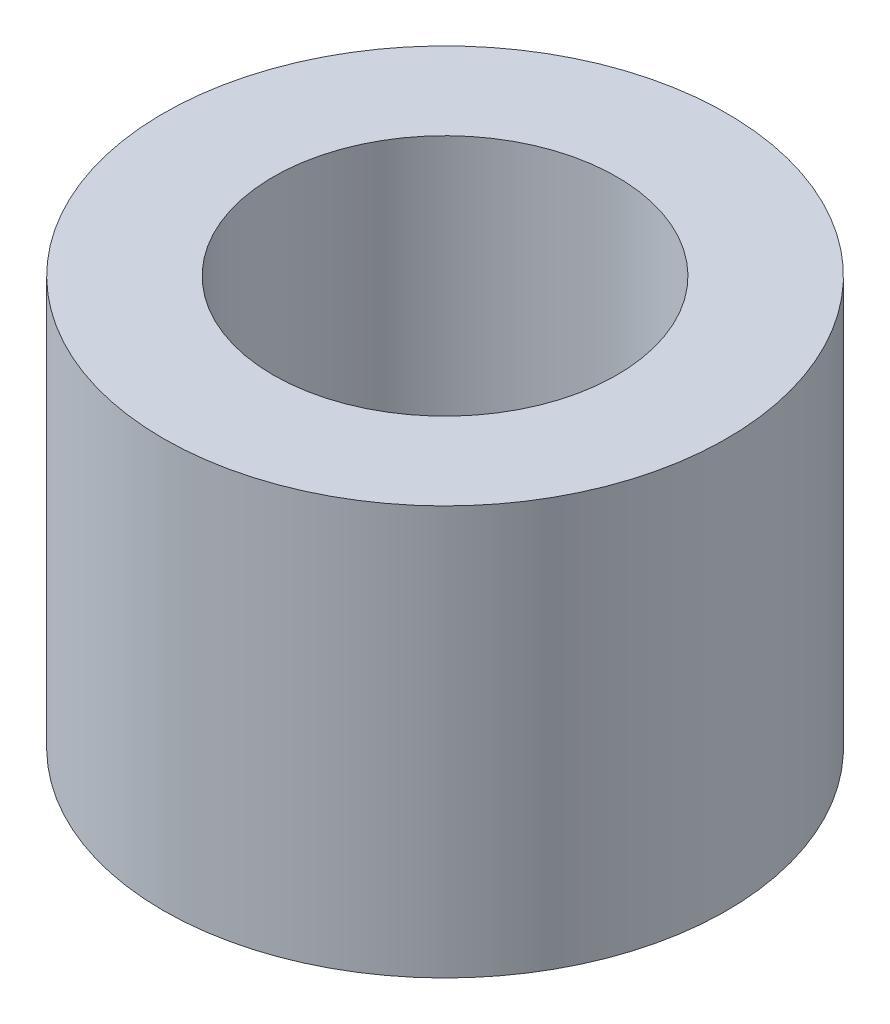
from build123d import *

# Parameters (mm, degrees)
SKETCH1_R               = 4.1
BOSS_EXTRUDE1_DEPTH     = 5.95
TAP_DRILL_FOR_M6_TAP1_D = 5


with BuildPart() as part:
    # Sketch1 → Boss-Extrude1 (new body)
    with BuildSketch(Plane(origin=(0, 0, 0), x_dir=(1, 0, 0), z_dir=(0, 1, 0))):
        with Locations((59.475545776, 35.570000001)):
            Circle(SKETCH1_R)
    extrude(amount=BOSS_EXTRUDE1_DEPTH)

    # Tap Drill for M6 Tap1 (through all)
    with Locations(Plane(origin=(0, 5.95, 0), x_dir=(1, 0, 0), z_dir=(0, 1, 0))):
        with Locations((59.475545776, 35.570000001)):
            Hole(TAP_DRILL_FOR_M6_TAP1_D / 2)


solid = part.part
